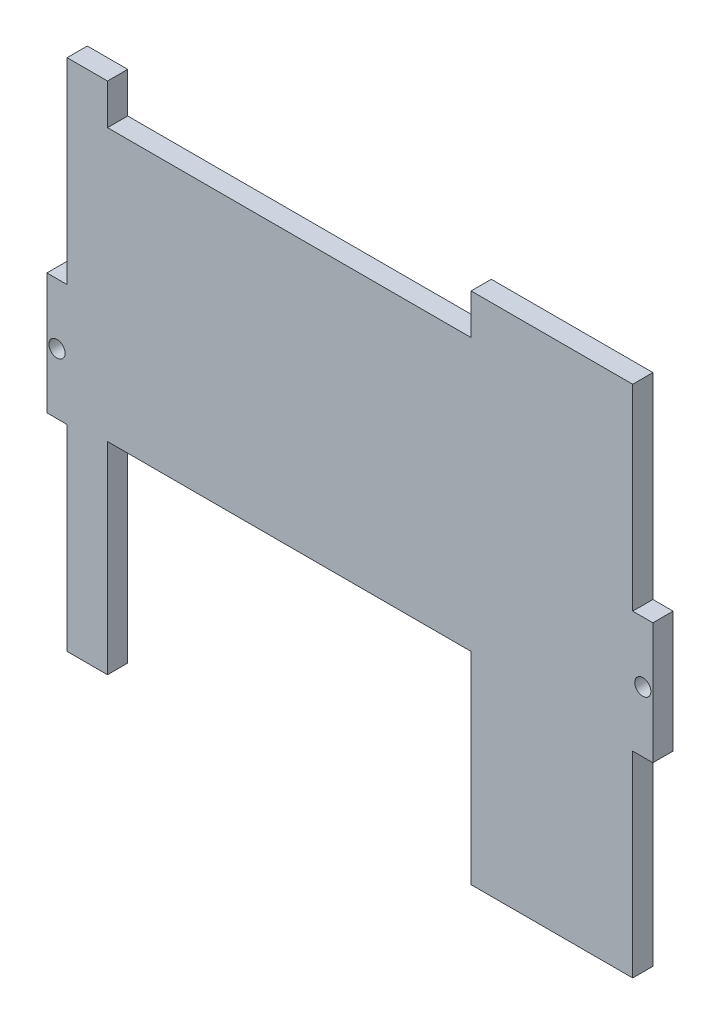
from build123d import *

# Parameters (mm, degrees)
BOSS_EXTRUDE1_DEPTH = 5
SKETCH2_R           = 2
CUT_EXTRUDE1_DEPTH  = 5
SKETCH3_W           = 90
SKETCH3_H           = 10
SKETCH3_H_2         = 50
CUT_EXTRUDE2_DEPTH  = 5


with BuildPart() as part:
    # Sketch1 → Boss-Extrude1 (new body)
    with BuildSketch(Plane.XY):
        Polygon((-70, -15), (-70, -63.64), (70, -63.64), (70, -15), (75, -15), (75, 15), (70, 15), (70, 63.64), (-70, 63.64), (-70, 15), (-75, 15), (-75, -15), align=None)
    extrude(amount=BOSS_EXTRUDE1_DEPTH)

    # Sketch2 → Cut-Extrude1 (cut)
    with BuildSketch(Plane.XY.offset(5)):
        with Locations((-72.5, 0)):
            Circle(SKETCH2_R)
        with Locations((72.5, 0)):
            Circle(SKETCH2_R)
    extrude(amount=-CUT_EXTRUDE1_DEPTH, mode=Mode.SUBTRACT)

    # Sketch3 → Cut-Extrude2 (cut)
    with BuildSketch(Plane.XY.offset(5)):
        with Locations((-15, 58.64)):
            Rectangle(SKETCH3_W, SKETCH3_H)
        with Locations((-15, -38.64)):
            Rectangle(SKETCH3_W, SKETCH3_H_2)
    extrude(amount=-CUT_EXTRUDE2_DEPTH, mode=Mode.SUBTRACT)


solid = part.part
